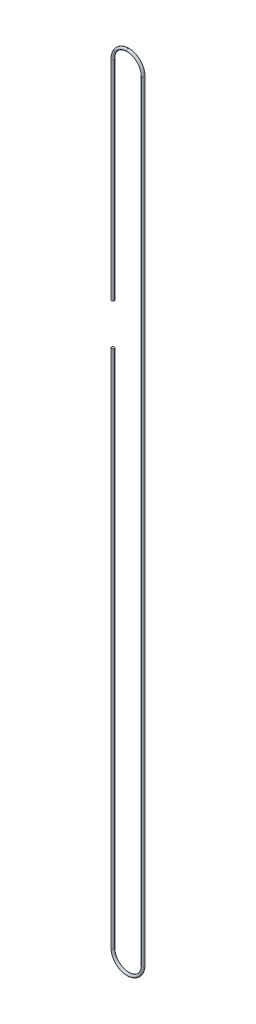
from build123d import *

# Parameters (mm, degrees)
SKETCH2_R               = 1.5875
SKETCH3_W               = 36.037797304
SKETCH3_H               = 47.625
CUT_EXTRUDE1_DEPTH      = 2.5875001
CUT_EXTRUDE1_DEPTH_BACK = 2.5875001


with BuildPart() as part:
    # Sweep1: sweep along a path in Sketch1
    with BuildLine(Plane.XY) as sweep1_path:
        Line((-17.4625, 889), (-17.4625, 0))
        ThreePointArc((-17.4625, 0), (0, -17.4625), (17.4625, 0))
        Line((17.4625, 0), (17.4625, 889))
        ThreePointArc((17.4625, 889), (0, 906.4625), (-17.4625, 889))
    # Sketch2 → Sweep1 (sweep)
    with BuildSketch(Plane(origin=(0, 0, 0), x_dir=(0, 0, -1), z_dir=(1, 0, 0))):
        with Locations((0, 906.4625)):
            Circle(SKETCH2_R)
    sweep(path=sweep1_path.line)

    # Sketch3 → Cut-Extrude1 (cut, two sides)
    with BuildSketch(Plane.XY) as cut_extrude1_sk:
        with Locations((-20.239587833, 623.8875)):
            Rectangle(SKETCH3_W, SKETCH3_H)
    extrude(amount=CUT_EXTRUDE1_DEPTH, mode=Mode.SUBTRACT)
    extrude(cut_extrude1_sk.sketch, amount=-CUT_EXTRUDE1_DEPTH_BACK, mode=Mode.SUBTRACT)


solid = part.part
